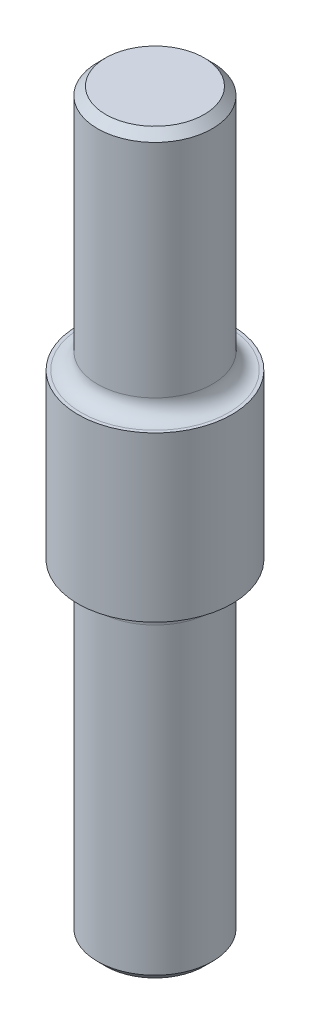
from build123d import *

# Parameters (mm, degrees)
SKETCH1_R           = 3.5
BOSS_EXTRUDE1_DEPTH = 20
SKETCH2_R           = 4.7
BOSS_EXTRUDE2_DEPTH = 10
SKETCH3_R           = 3.5
BOSS_EXTRUDE3_DEPTH = 15
FILLET1_R           = 1
CHAMFER1_SIZE       = 0.5


with BuildPart() as part:
    # Sketch1 → Boss-Extrude1 (new body)
    with BuildSketch(Plane(origin=(0, 0, 0), x_dir=(1, 0, 0), z_dir=(0, 1, 0))):
        Circle(SKETCH1_R)
    extrude(amount=BOSS_EXTRUDE1_DEPTH)

    # Sketch2 → Boss-Extrude2 (add)
    with BuildSketch(Plane(origin=(0, 20, 0), x_dir=(1, 0, 0), z_dir=(0, 1, 0))):
        Circle(SKETCH2_R)
    extrude(amount=BOSS_EXTRUDE2_DEPTH)

    # Sketch3 → Boss-Extrude3 (add)
    with BuildSketch(Plane(origin=(0, 30, 0), x_dir=(1, 0, 0), z_dir=(0, 1, 0))):
        Circle(SKETCH3_R)
    extrude(amount=BOSS_EXTRUDE3_DEPTH)

    # Fillet1
    fillet1_edges = [part.edges().sort_by_distance(p)[0] for p in [
        (-3.5, 30, 0),
        (-3.5, 20, 0),
    ]]
    fillet(fillet1_edges, radius=FILLET1_R)

    # Chamfer1
    chamfer1_edges = [part.edges().sort_by_distance(p)[0] for p in [
        (-3.5, 45, 0),
        (-3.5, 0, 0),
    ]]
    chamfer(chamfer1_edges, length=CHAMFER1_SIZE)


solid = part.part
